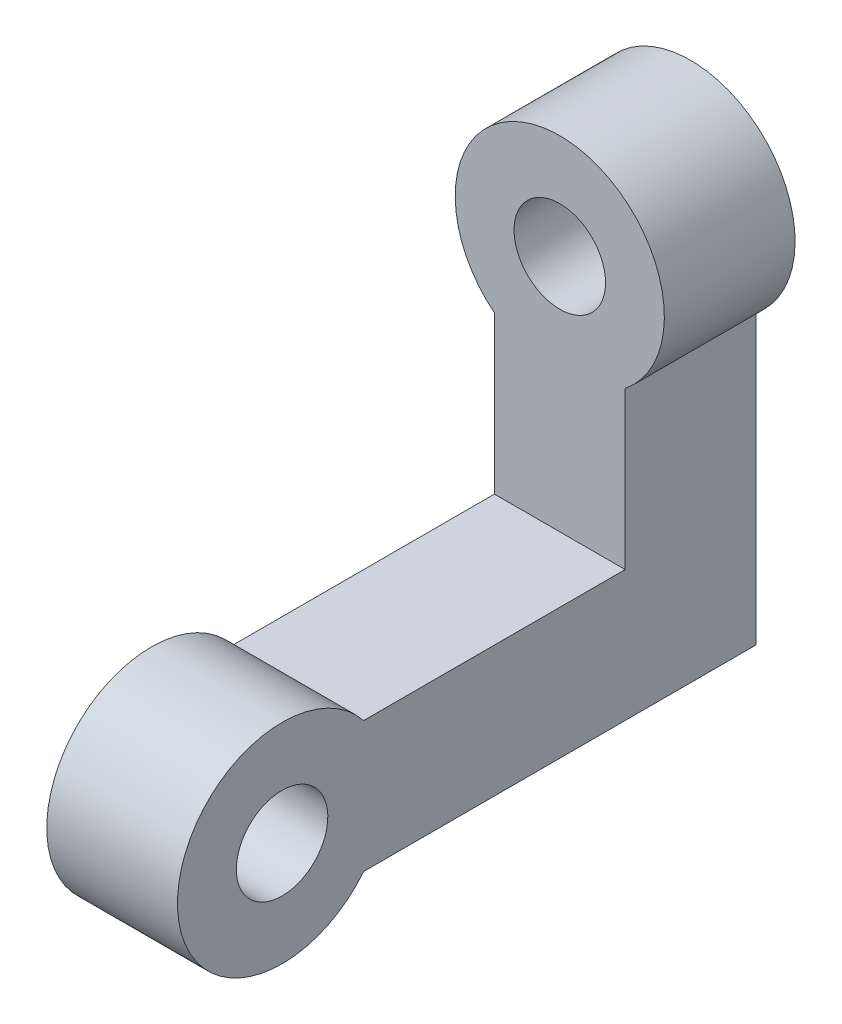
from build123d import *

# Parameters (mm, degrees)
ESBO_O1_R                = 1.75
RESSALTO_EXTRUS_O1_DEPTH = 5
ESBO_O2_R                = 1.75
RESSALTO_EXTRUS_O2_DEPTH = 5


with BuildPart() as part:
    # Esboço1 → Ressalto-extrusão1 (new body)
    with BuildSketch(Plane.XY):
        with BuildLine():
            Line((-2.5, -3.122498999), (-2.5, -9.122498999))
            Line((-2.5, -9.122498999), (2.5, -9.122498999))
            Line((2.5, -9.122498999), (2.5, -3.122498999))
            ThreePointArc((2.5, -3.122498999), (0, 4), (-2.5, -3.122498999))
        make_face()
        Circle(ESBO_O1_R, mode=Mode.SUBTRACT)
    extrude(amount=RESSALTO_EXTRUS_O1_DEPTH)

    # Esboço2 → Ressalto-extrusão2 (add)
    with BuildSketch(Plane.ZY.offset(2.5)):
        with BuildLine():
            Line((0, -9.122498999), (0, -14.122498999))
            Line((0, -14.122498999), (15, -14.122498999))
            ThreePointArc((15, -14.122498999), (22.122498999, -11.622498999), (15, -9.122498999))
            Line((15, -9.122498999), (0, -9.122498999))
        make_face()
        with Locations((18.122498999, -11.622498999)):
            Circle(ESBO_O2_R, mode=Mode.SUBTRACT)
    extrude(amount=-RESSALTO_EXTRUS_O2_DEPTH)


solid = part.part
